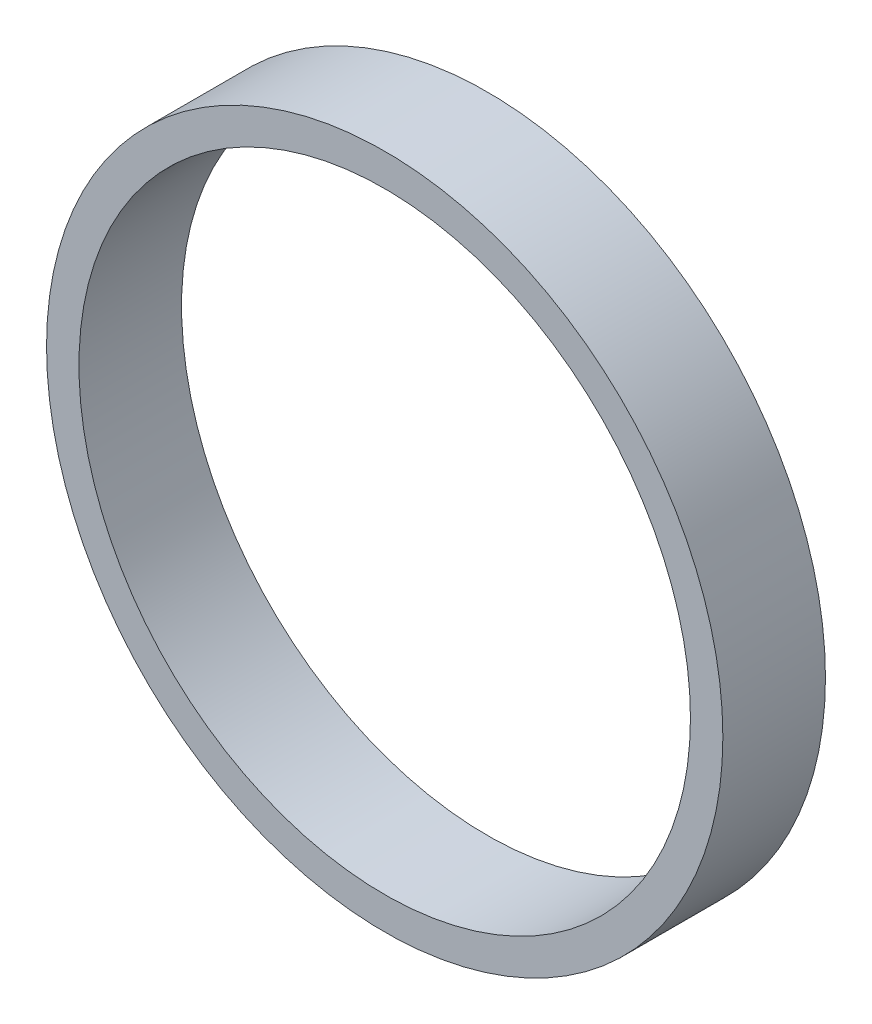
from build123d import *

# Parameters (mm, degrees)
SKETCH1_R           = 62.7888
SKETCH1_R_2         = 56.769
BOSS_EXTRUDE1_DEPTH = 19.05


with BuildPart() as part:
    # Sketch1 → Boss-Extrude1 (new body)
    with BuildSketch(Plane.XY):
        Circle(SKETCH1_R)
        Circle(SKETCH1_R_2, mode=Mode.SUBTRACT)
    extrude(amount=BOSS_EXTRUDE1_DEPTH)


solid = part.part
